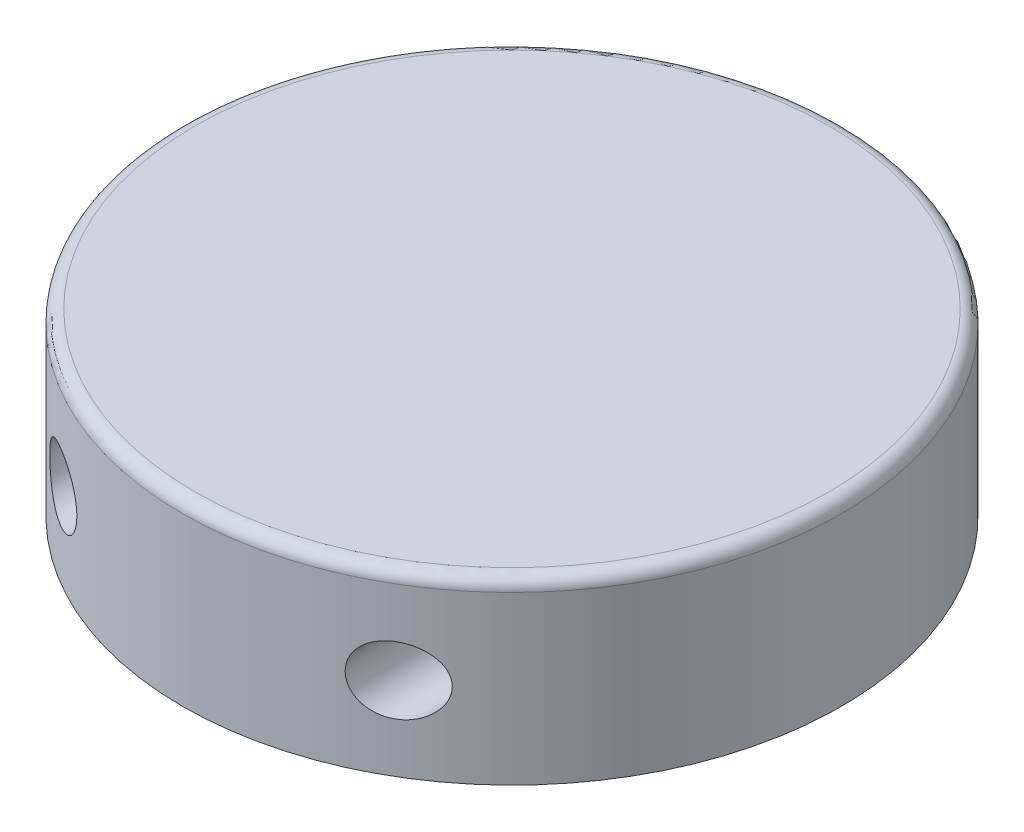
from build123d import *

# Parameters (mm, degrees)
SKETCH1_R           = 39.3
BOSS_EXTRUDE1_DEPTH = 21.4
FILLET1_R           = 1.5
SKETCH2_R           = 4
CUT_EXTRUDE1_DEPTH  = 50


with BuildPart() as part:
    # Sketch1 → Boss-Extrude1 (new body)
    with BuildSketch(Plane(origin=(0, 0, 0), x_dir=(1, 0, 0), z_dir=(0, 1, 0))):
        Circle(SKETCH1_R)
    extrude(amount=BOSS_EXTRUDE1_DEPTH)

    # Fillet1
    fillet1_edges = [part.edges().sort_by_distance(p)[0] for p in [
        (-39.3, 21.4, 0),
    ]]
    fillet(fillet1_edges, radius=FILLET1_R)

    # Sketch2 → Cut-Extrude1 (cut)
    with BuildSketch(Plane.XY.offset(39.3)):
        with Locations((-20, 9.95)):
            Circle(SKETCH2_R)
        with Locations((20, 9.95)):
            Circle(SKETCH2_R)
    extrude(amount=-CUT_EXTRUDE1_DEPTH, mode=Mode.SUBTRACT)


solid = part.part
